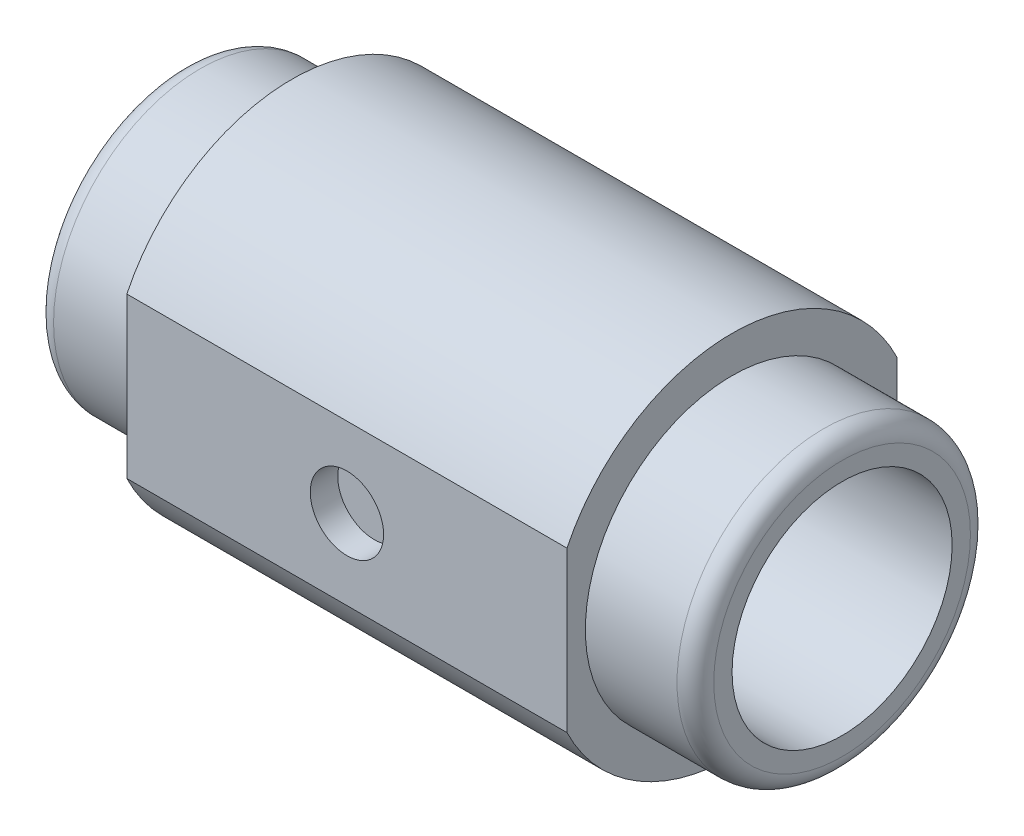
from build123d import *

# Parameters (mm, degrees)
BOSS_EXTRUDE1_DEPTH      = 9.6774
BOSS_EXTRUDE1_DEPTH_BACK = 9.6774
SKETCH2_R                = 6.4516
BOSS_EXTRUDE2_DEPTH      = 4.8387
SKETCH3_R                = 4.8387
CUT_EXTRUDE1_DEPTH       = 30.0322
FILLET1_R                = 0.80772
SKETCH4_R                = 1.6129
CUT_EXTRUDE2_DEPTH       = 1.20904


with BuildPart() as part:
    # Sketch1 → Boss-Extrude1 (new body, two sides)
    with BuildSketch(Plane(origin=(0, 0, 0), x_dir=(0, 0, -1), z_dir=(1, 0, 0))) as boss_extrude1_sk:
        with BuildLine():
            Line((-7.25932, 3.512610623), (-7.25932, -3.512610623))
            ThreePointArc((-7.25932, -3.512610623), (0, -8.0645), (7.25932, -3.512610623))
            Line((7.25932, -3.512610623), (7.25932, 3.512610623))
            ThreePointArc((7.25932, 3.512610623), (0, 8.0645), (-7.25932, 3.512610623))
        make_face()
    extrude(amount=BOSS_EXTRUDE1_DEPTH)
    extrude(boss_extrude1_sk.sketch, amount=-BOSS_EXTRUDE1_DEPTH_BACK)

    # Sketch2 → Boss-Extrude2 (add)
    with BuildSketch(Plane(origin=(9.6774, 0, 0), x_dir=(0, 0, -1), z_dir=(1, 0, 0))):
        Circle(SKETCH2_R)
    boss_extrude2 = extrude(amount=BOSS_EXTRUDE2_DEPTH)

    # Mirror1: Boss-Extrude2 across plane
    add(boss_extrude2.mirror(Plane(origin=(0, 0, 0), x_dir=(0, 0, 1), z_dir=(1, 0, 0))))

    # Sketch3 → Cut-Extrude1 (cut, through all)
    with BuildSketch(Plane(origin=(14.5161, 0, 0), x_dir=(0, 0, -1), z_dir=(1, 0, 0))):
        Circle(SKETCH3_R)
    extrude(amount=-CUT_EXTRUDE1_DEPTH, mode=Mode.SUBTRACT)

    # Fillet1
    fillet1_edges = [part.edges().sort_by_distance(p)[0] for p in [
        (14.5161, 0, 6.4516),
        (-14.5161, 0, 6.4516),
    ]]
    fillet(fillet1_edges, radius=FILLET1_R)

    # Sketch4 → Cut-Extrude2 (cut)
    with BuildSketch(Plane.XY.offset(7.25932)):
        Circle(SKETCH4_R)
    extrude(amount=-CUT_EXTRUDE2_DEPTH, mode=Mode.SUBTRACT)


solid = part.part
